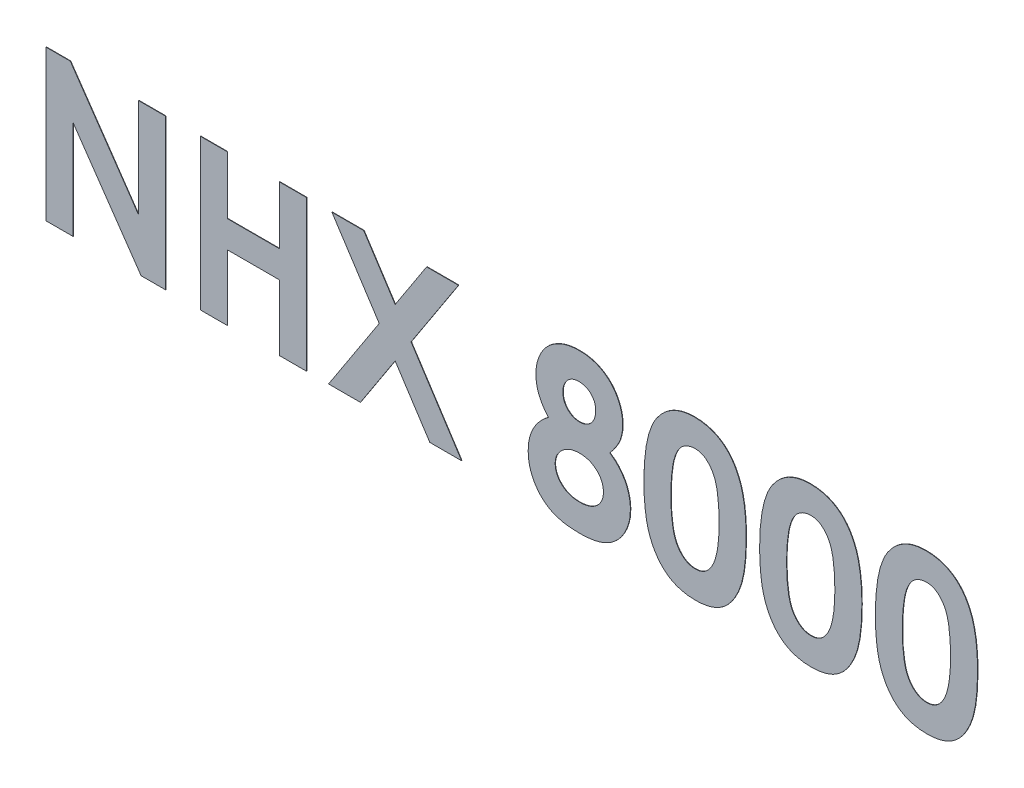
from build123d import *

# Parameters (mm, degrees)
ESTRUSIONE_ESTRUSIONE1_DEPTH   = 0.01
ESTRUSIONE_ESTRUSIONE1_2_DEPTH = 0.01
ESTRUSIONE_ESTRUSIONE1_3_DEPTH = 0.01
ESTRUSIONE_ESTRUSIONE1_4_DEPTH = 0.01
ESTRUSIONE_ESTRUSIONE1_5_DEPTH = 0.01
ESTRUSIONE_ESTRUSIONE1_6_DEPTH = 0.01
ESTRUSIONE_ESTRUSIONE1_7_DEPTH = 0.01
SCALA1_SCALE                   = 40


with BuildPart() as part:
    # Schizzo1 → Estrusione-Estrusione1 (new body)
    with BuildSketch(Plane.XY):
        Polygon((0.403846154, 3.5), (0.969651442, 3.5), (2.557692308, 1.196814904), (2.557692308, 3.5), (3.185897436, 3.5), (3.185897436, 0), (2.615885417, 0), (1.032051282, 2.296173878), (1.032051282, 0), (0.403846154, 0), align=None)
    extrude(amount=ESTRUSIONE_ESTRUSIONE1_DEPTH)


with BuildPart() as body_2:
    # Schizzo1 → Estrusione-Estrusione1 2 (new body)
    with BuildSketch(Plane.XY):
        Polygon((3.993589744, 3.5), (4.621794872, 3.5), (4.621794872, 2.153846154), (5.833333333, 2.153846154), (5.833333333, 3.5), (6.461538462, 3.5), (6.461538462, 0), (5.833333333, 0), (5.833333333, 1.525641026), (4.621794872, 1.525641026), (4.621794872, 0), (3.993589744, 0), align=None)
    extrude(amount=ESTRUSIONE_ESTRUSIONE1_2_DEPTH)


with BuildPart() as body_3:
    # Schizzo1 → Estrusione-Estrusione1 3 (new body)
    with BuildSketch(Plane.XY):
        Polygon((7.055388622, 3.5), (7.795773237, 3.5), (8.527043269, 2.376101763), (9.259715545, 3.5), (10.000801282, 3.5), (8.897235577, 1.807491987), (10.073717949, 0), (9.333333333, 0), (8.527043269, 1.239583333), (7.71864984, 0), (6.977564103, 0), (8.156850962, 1.808193109), align=None)
    extrude(amount=ESTRUSIONE_ESTRUSIONE1_3_DEPTH)


with BuildPart() as body_4:
    # Schizzo1 → Estrusione-Estrusione1 4 (new body)
    with BuildSketch(Plane.XY):
        with BuildLine():
            add(Edge.make_bspline(
                [(13.520432692, 1.884615385), (13.557134601, 1.85839088), (13.629782717, 1.806481838), (13.725724304, 1.713484848), (13.808363459, 1.609745628), (13.87683238, 1.495900492), (13.931687615, 1.374747784), (13.97095564, 1.247582481), (13.995898238, 1.115526214), (13.998622715, 1.025618623), (14, 0.980168269)],
                knots=[0, 0, 0, 0, 0.000135177, 0.00026757, 0.000399295, 0.000532042, 0.000665095, 0.000797263, 0.000930523, 0.001066759, 0.001066759, 0.001066759, 0.001066759], degree=3))
            add(Edge.make_bspline(
                [(14, 0.980168269), (13.99833841, 0.930953536), (13.995042859, 0.833342428), (13.965905788, 0.690195753), (13.919127389, 0.552673083), (13.855195578, 0.422292319), (13.775036845, 0.303105196), (13.681604387, 0.197590627), (13.574780425, 0.108504305), (13.47532429, 0.048059811), (13.38971892, 0.007907676), (13.320636138, -0.017788884), (13.247689261, -0.04041111), (13.17035775, -0.058484767), (13.088655668, -0.072594223), (13.002699613, -0.081912081), (12.912433003, -0.088685596), (12.850874991, -0.089384979), (12.819310897, -0.08974359)],
                knots=[0, 0, 0, 0, 0.000147517, 0.000292582, 0.000436255, 0.000582373, 0.000726855, 0.000865897, 0.001003783, 0.001142545, 0.001213746, 0.00128719, 0.00136348, 0.001442728, 0.001525259, 0.001612053, 0.001702019, 0.001796693, 0.001796693, 0.001796693, 0.001796693], degree=3))
            add(Edge.make_bspline(
                [(12.819310897, -0.08974359), (12.785650923, -0.089287007), (12.71991963, -0.08839539), (12.623966585, -0.083004204), (12.533454516, -0.073064948), (12.448193559, -0.059980687), (12.368265746, -0.042666417), (12.293668707, -0.020712871), (12.224222321, 0.004283683), (12.139216297, 0.042343082), (12.042069826, 0.101780984), (11.93707206, 0.188826078), (11.844910884, 0.292499504), (11.76478547, 0.409891165), (11.701627599, 0.540278868), (11.654661523, 0.679570167), (11.626847657, 0.8273876), (11.623499179, 0.928635274), (11.621794872, 0.980168269)],
                knots=[0, 0, 0, 0, 0.000100983, 0.000197201, 0.000288177, 0.000374052, 0.000455879, 0.000533311, 0.000607169, 0.000677148, 0.00081242, 0.000947344, 0.001084873, 0.00122722, 0.001372399, 0.001518066, 0.00166713, 0.001821645, 0.001821645, 0.001821645, 0.001821645], degree=3))
            add(Edge.make_bspline(
                [(11.621794872, 0.980168269), (11.623352323, 1.02512233), (11.626412903, 1.113462503), (11.64833625, 1.242908796), (11.685928128, 1.365639198), (11.737510036, 1.482508108), (11.804024031, 1.59352853), (11.885863437, 1.697883573), (11.981990615, 1.796514663), (12.054885649, 1.854761362), (12.092247596, 1.884615385)],
                knots=[0, 0, 0, 0, 0.000134836, 0.000264969, 0.000392498, 0.000519, 0.000647297, 0.000779691, 0.000916035, 0.001059397, 0.001059397, 0.001059397, 0.001059397], degree=3))
            add(Edge.make_bspline(
                [(12.092247596, 1.884615385), (12.069085171, 1.911329853), (12.023485331, 1.963922597), (11.96447869, 2.048566426), (11.91476808, 2.135834303), (11.872561405, 2.225018003), (11.841361155, 2.317653045), (11.817766573, 2.412283019), (11.8044215, 2.509871987), (11.802335625, 2.575649851), (11.801282051, 2.608874199)],
                knots=[0, 0, 0, 0, 0.000106018, 0.000208717, 0.000308899, 0.000407081, 0.000504196, 0.000601634, 0.000699302, 0.000798982, 0.000798982, 0.000798982, 0.000798982], degree=3))
            add(Edge.make_bspline(
                [(11.801282051, 2.608874199), (11.80267893, 2.653850171), (11.805434918, 2.742586032), (11.829844543, 2.872338813), (11.870370447, 2.995629814), (11.925502491, 3.11209806), (11.995511619, 3.21920525), (12.078697619, 3.315256457), (12.176229923, 3.39673336), (12.284481567, 3.46664414), (12.40399516, 3.522250526), (12.533636768, 3.56115971), (12.671840951, 3.585791276), (12.767087147, 3.58840611), (12.815805288, 3.58974359)],
                knots=[0, 0, 0, 0, 0.000134836, 0.000266026, 0.000394401, 0.000523295, 0.000651447, 0.000777159, 0.000903019, 0.001031378, 0.00116281, 0.001296988, 0.001436461, 0.001582498, 0.001582498, 0.001582498, 0.001582498], degree=3))
            add(Edge.make_bspline(
                [(12.815805288, 3.58974359), (12.863821761, 3.588403921), (12.957443829, 3.585791847), (13.093219257, 3.561323492), (13.220059285, 3.521547598), (13.336915038, 3.464767113), (13.44404715, 3.394721588), (13.539921818, 3.310407735), (13.622846778, 3.211964217), (13.693437026, 3.102086196), (13.749686607, 2.983708548), (13.791271722, 2.859565009), (13.815325045, 2.730631358), (13.818776647, 2.643091493), (13.820512821, 2.599058494)],
                knots=[0, 0, 0, 0, 0.000143937, 0.000280646, 0.000412357, 0.000541553, 0.000669119, 0.000795294, 0.000923131, 0.001054017, 0.001186046, 0.001315306, 0.001445807, 0.001577886, 0.001577886, 0.001577886, 0.001577886], degree=3))
            add(Edge.make_bspline(
                [(13.820512821, 2.599058494), (13.819676464, 2.567938351), (13.818035177, 2.506867397), (13.80589983, 2.416892646), (13.785465395, 2.330561752), (13.756975166, 2.245788452), (13.717364023, 2.160268983), (13.663760936, 2.072364636), (13.598559819, 1.978422968), (13.547354125, 1.916940066), (13.520432692, 1.884615385)],
                knots=[0, 0, 0, 0, 9.3344e-05, 0.000183181, 0.000271783, 0.00035914, 0.000451054, 0.000553861, 0.000667646, 0.000793787, 0.000793787, 0.000793787, 0.000793787], degree=3))
        make_face()
        with BuildLine():
            add(Edge.make_bspline(
                [(12.800380609, 2.961538462), (12.774516092, 2.960291552), (12.724203892, 2.957866039), (12.652414274, 2.935973092), (12.587873065, 2.90016562), (12.532053546, 2.850887492), (12.48627863, 2.791095866), (12.452636582, 2.722353174), (12.43268645, 2.645507777), (12.43057434, 2.591699174), (12.429487179, 2.564002404)],
                knots=[0, 0, 0, 0, 7.7441e-05, 0.000150641, 0.000222826, 0.000297356, 0.000372379, 0.000447321, 0.000525545, 0.000608518, 0.000608518, 0.000608518, 0.000608518], degree=3))
            add(Edge.make_bspline(
                [(12.429487179, 2.564002404), (12.430830156, 2.536069098), (12.433452446, 2.481526625), (12.454073813, 2.403204778), (12.489223504, 2.332222912), (12.537483792, 2.270063604), (12.596127857, 2.219293679), (12.661791232, 2.180518436), (12.735202136, 2.158382655), (12.78621567, 2.155380965), (12.812299679, 2.153846154)],
                knots=[0, 0, 0, 0, 8.3728e-05, 0.000163486, 0.000240934, 0.00031989, 0.000397917, 0.000472358, 0.000547102, 0.000625308, 0.000625308, 0.000625308, 0.000625308], degree=3))
            add(Edge.make_bspline(
                [(12.812299679, 2.153846154), (12.838876821, 2.155035369), (12.89065408, 2.157352184), (12.964248281, 2.180062326), (13.030547252, 2.21638257), (13.087322525, 2.267731361), (13.134349892, 2.32991318), (13.168598837, 2.402135517), (13.188311293, 2.483041407), (13.190942976, 2.539587197), (13.192307692, 2.568910256)],
                knots=[0, 0, 0, 0, 7.9536e-05, 0.000154952, 0.000228703, 0.000304687, 0.000382792, 0.000461195, 0.000542818, 0.000630738, 0.000630738, 0.000630738, 0.000630738], degree=3))
            add(Edge.make_bspline(
                [(13.192307692, 2.568910256), (13.190908454, 2.596588717), (13.188202376, 2.650117887), (13.168798761, 2.726968269), (13.133163051, 2.794638052), (13.086342326, 2.854058384), (13.027641684, 2.901977186), (12.959494539, 2.937216962), (12.882402697, 2.957656374), (12.82831337, 2.96021641), (12.800380609, 2.961538462)],
                knots=[0, 0, 0, 0, 8.3029e-05, 0.000160575, 0.00023552, 0.000310854, 0.000386083, 0.000461028, 0.000539431, 0.000623159, 0.000623159, 0.000623159, 0.000623159], degree=3))
        make_face(mode=Mode.SUBTRACT)
        with BuildLine():
            add(Edge.make_bspline(
                [(12.820713141, 1.525641026), (12.801058066, 1.525314624), (12.762318159, 1.52467129), (12.705367311, 1.517252686), (12.650717121, 1.50619713), (12.598435388, 1.490946303), (12.548786239, 1.470155589), (12.501348813, 1.445091998), (12.456286937, 1.41550217), (12.414269006, 1.381923308), (12.376294614, 1.345067308), (12.342064154, 1.306627695), (12.314085586, 1.2656107), (12.290786109, 1.223379742), (12.272064848, 1.179600163), (12.259688679, 1.133551003), (12.251720159, 1.085845509), (12.25057676, 1.053350461), (12.25, 1.036959135)],
                knots=[0, 0, 0, 0, 5.8932e-05, 0.000116154, 0.00017198, 0.000226107, 0.000279231, 0.000333176, 0.000386848, 0.00044072, 0.000494272, 0.000545454, 0.000594852, 0.000642862, 0.000689999, 0.000737287, 0.000785583, 0.000834742, 0.000834742, 0.000834742, 0.000834742], degree=3))
            add(Edge.make_bspline(
                [(12.25, 1.036959135), (12.250274894, 1.0198646), (12.250820112, 0.985959705), (12.259054864, 0.936472773), (12.270911454, 0.888746025), (12.287564412, 0.843226213), (12.30983458, 0.799939838), (12.336425565, 0.758466064), (12.368264584, 0.719095711), (12.404488331, 0.682039869), (12.445040656, 0.648608885), (12.488747175, 0.619155605), (12.535030625, 0.593188086), (12.585280402, 0.57448525), (12.637635557, 0.557366772), (12.6934987, 0.546981403), (12.752259681, 0.539339561), (12.79240676, 0.538759229), (12.813000801, 0.538461538)],
                knots=[0, 0, 0, 0, 5.1225e-05, 0.000101599, 0.000150062, 0.000198643, 0.000246617, 0.00029582, 0.000346189, 0.000398247, 0.000451032, 0.000503536, 0.000556247, 0.000609757, 0.000664089, 0.000721289, 0.000779903, 0.000841638, 0.000841638, 0.000841638, 0.000841638], degree=3))
            add(Edge.make_bspline(
                [(12.813000801, 0.538461538), (12.833818314, 0.538838881), (12.874385053, 0.539574201), (12.933685468, 0.546073039), (12.989773136, 0.556384806), (13.042581063, 0.571133034), (13.092308944, 0.590026101), (13.138289721, 0.614073237), (13.181573212, 0.641325334), (13.220768498, 0.673163934), (13.256556683, 0.707861361), (13.28739323, 0.745886791), (13.313613203, 0.786017464), (13.334762469, 0.828686989), (13.351828027, 0.873693952), (13.363533929, 0.921487118), (13.370797862, 0.971529403), (13.371458967, 1.005616963), (13.371794872, 1.022936699)],
                knots=[0, 0, 0, 0, 6.2435e-05, 0.000121667, 0.000178734, 0.00023334, 0.000285943, 0.000337996, 0.000388759, 0.000439127, 0.000489202, 0.00053804, 0.000585685, 0.000632718, 0.000680641, 0.000729785, 0.000780056, 0.000831981, 0.000831981, 0.000831981, 0.000831981], degree=3))
            add(Edge.make_bspline(
                [(13.371794872, 1.022936699), (13.371153492, 1.040482865), (13.369899818, 1.074779539), (13.363039895, 1.125426645), (13.350171381, 1.173440894), (13.333335605, 1.219935855), (13.310940157, 1.263949395), (13.283136693, 1.305388621), (13.251489526, 1.345280033), (13.214500981, 1.381847811), (13.174059758, 1.415283757), (13.131016523, 1.445071515), (13.085503852, 1.470298998), (13.037397255, 1.490921213), (12.986520961, 1.506205066), (12.933263157, 1.517252297), (12.877711207, 1.52467295), (12.839901481, 1.525315124), (12.820713141, 1.525641026)],
                knots=[0, 0, 0, 0, 5.2659e-05, 0.00010293, 0.000152926, 0.000201506, 0.000251049, 0.000300635, 0.000351004, 0.000403555, 0.00045634, 0.000508266, 0.000560361, 0.000612192, 0.000664977, 0.00071943, 0.000775261, 0.000832791, 0.000832791, 0.000832791, 0.000832791], degree=3))
        make_face(mode=Mode.SUBTRACT)
    extrude(amount=ESTRUSIONE_ESTRUSIONE1_4_DEPTH)


with BuildPart() as body_5:
    # Schizzo1 → Estrusione-Estrusione1 5 (new body)
    with BuildSketch(Plane.XY):
        with BuildLine():
            add(Edge.make_bspline(
                [(15.492688301, 3.58974359), (15.523096037, 3.589292178), (15.582885769, 3.588404583), (15.670944791, 3.578791201), (15.755769975, 3.564268063), (15.837693169, 3.544013349), (15.916124681, 3.517206957), (15.991635353, 3.485120165), (16.063326387, 3.446069956), (16.132112075, 3.401960738), (16.19796592, 3.352022851), (16.25930517, 3.29509108), (16.317250012, 3.23247543), (16.370546152, 3.163229263), (16.420373849, 3.087982447), (16.466569379, 3.00672305), (16.508779103, 2.919053361), (16.547476091, 2.824815174), (16.582079059, 2.722595899), (16.611225097, 2.611223037), (16.636222702, 2.490671153), (16.657322443, 2.360640176), (16.673270438, 2.220957264), (16.684019708, 2.071715214), (16.691396365, 1.913201744), (16.691998396, 1.804462806), (16.692307692, 1.748597756)],
                knots=[0, 0, 0, 0, 9.1189e-05, 0.000179302, 0.000265406, 0.000349239, 0.000432161, 0.00051382, 0.000595069, 0.000676752, 0.000758786, 0.000842642, 0.00092749, 0.00101444, 0.001104474, 0.001198046, 0.001294628, 0.001396185, 0.001503495, 0.001618119, 0.001741326, 0.001872727, 0.002013179, 0.002162939, 0.002321548, 0.002489129, 0.002489129, 0.002489129, 0.002489129], degree=3))
            add(Edge.make_bspline(
                [(16.692307692, 1.748597756), (16.691973427, 1.692033772), (16.691323955, 1.582130965), (16.684326357, 1.42216765), (16.672276163, 1.271842014), (16.656745002, 1.131169608), (16.635471561, 1.000224719), (16.610557404, 0.878668289), (16.580951305, 0.766544378), (16.545208525, 0.664105625), (16.506745771, 0.569701935), (16.464420586, 0.482203181), (16.418970691, 0.401372369), (16.371438571, 0.325990055), (16.31921834, 0.258278471), (16.264851703, 0.195935071), (16.20597144, 0.141334593), (16.145056639, 0.091663175), (16.079875742, 0.048737102), (16.011100945, 0.011194666), (15.937506111, -0.019256709), (15.860432749, -0.045741688), (15.778567128, -0.064755045), (15.693210081, -0.07984152), (15.603397946, -0.088179231), (15.542250227, -0.089213579), (15.510917468, -0.08974359)],
                knots=[0, 0, 0, 0, 0.000169685, 0.000329694, 0.000480207, 0.000622052, 0.000754146, 0.000878038, 0.000994198, 0.001101735, 0.001203292, 0.001299874, 0.001393102, 0.001481398, 0.001566938, 0.001649385, 0.001729242, 0.001807533, 0.001884926, 0.001963041, 0.002042215, 0.002123584, 0.00220725, 0.002294045, 0.002383484, 0.002477476, 0.002477476, 0.002477476, 0.002477476], degree=3))
            add(Edge.make_bspline(
                [(15.510917468, -0.08974359), (15.479585555, -0.089203355), (15.418206798, -0.088145043), (15.328151802, -0.079903514), (15.242342406, -0.06469393), (15.159829097, -0.045595718), (15.081186153, -0.01931531), (15.006036485, 0.012047148), (14.934957928, 0.049355338), (14.867753677, 0.092381425), (14.804653186, 0.141720504), (14.744675875, 0.196844838), (14.687954416, 0.257614701), (14.635351683, 0.324710765), (14.586006197, 0.397237439), (14.540432551, 0.476022941), (14.498658136, 0.560952561), (14.459376239, 0.652144684), (14.425245243, 0.75156257), (14.394870241, 0.860094009), (14.369987838, 0.9786437), (14.349975745, 1.107173557), (14.333998101, 1.245411285), (14.322112571, 1.393423606), (14.315076104, 1.551279462), (14.314433444, 1.659781655), (14.314102564, 1.715645032)],
                knots=[0, 0, 0, 0, 9.3992e-05, 0.000184129, 0.000270924, 0.000355272, 0.000437971, 0.000519356, 0.000599327, 0.000678482, 0.000758422, 0.000839307, 0.000922649, 0.001007511, 0.001094825, 0.001185617, 0.00128031, 0.001378632, 0.00148329, 0.001595393, 0.001716541, 0.001846447, 0.001985506, 0.002133922, 0.00229183, 0.002459412, 0.002459412, 0.002459412, 0.002459412], degree=3))
            add(Edge.make_bspline(
                [(14.314102564, 1.715645032), (14.314701922, 1.793262797), (14.315858391, 1.943027275), (14.330514011, 2.159393402), (14.352024745, 2.359386406), (14.383618917, 2.542671749), (14.422684674, 2.709928265), (14.47271041, 2.860054156), (14.529661071, 2.995126752), (14.578190351, 3.075144571), (14.6015625, 3.113681891)],
                knots=[0, 0, 0, 0, 0.00023281, 0.000449211, 0.000650286, 0.000835979, 0.001006883, 0.001164965, 0.001310334, 0.001445389, 0.001445389, 0.001445389, 0.001445389], degree=3))
            add(Edge.make_bspline(
                [(14.6015625, 3.113681891), (14.628738522, 3.151540942), (14.681873, 3.225562848), (14.77478012, 3.322739774), (14.874596724, 3.405850239), (14.983372988, 3.47301338), (15.09938857, 3.525978238), (15.223639524, 3.563386721), (15.35566701, 3.585182647), (15.446332487, 3.588200572), (15.492688301, 3.58974359)],
                knots=[0, 0, 0, 0, 0.000139664, 0.000273071, 0.000402072, 0.00052834, 0.000655415, 0.000783615, 0.000916514, 0.00105555, 0.00105555, 0.00105555, 0.00105555], degree=3))
        make_face()
        with BuildLine():
            add(Edge.make_bspline(
                [(15.508112981, 2.961538462), (15.480624136, 2.960235545), (15.426731407, 2.957681137), (15.348530491, 2.935997815), (15.274791909, 2.902506756), (15.218700939, 2.862205503), (15.176717406, 2.823571918), (15.147383211, 2.788609781), (15.119095003, 2.749594555), (15.094109432, 2.704765685), (15.070516532, 2.655733924), (15.047459157, 2.602276698), (15.028558164, 2.543080981), (15.00998844, 2.479154885), (14.993719628, 2.408731022), (14.980089931, 2.331233756), (14.967912995, 2.246159114), (14.959419436, 2.153451372), (14.951500891, 2.053207526), (14.945824502, 1.945204271), (14.943451347, 1.829470744), (14.942696993, 1.749766781), (14.942307692, 1.708633814)],
                knots=[0, 0, 0, 0, 8.233e-05, 0.000161411, 0.000241719, 0.000324202, 0.000367359, 0.000412607, 0.000460858, 0.000511731, 0.000566293, 0.000624109, 0.000686189, 0.000752544, 0.000823804, 0.000902881, 0.00098855, 0.001081546, 0.001182103, 0.001290221, 0.00140594, 0.001529346, 0.001529346, 0.001529346, 0.001529346], degree=3))
            add(Edge.make_bspline(
                [(14.942307692, 1.708633814), (14.942948434, 1.655344067), (14.944177104, 1.553157026), (14.950612303, 1.406208503), (14.963511126, 1.272473515), (14.979554657, 1.151045689), (15.002088451, 1.042712518), (15.02801504, 0.94644907), (15.060032073, 0.86348247), (15.097033923, 0.792612834), (15.138015139, 0.732324181), (15.182502051, 0.681078555), (15.228980041, 0.636702261), (15.278899836, 0.600655944), (15.332142344, 0.573031708), (15.388263087, 0.553161936), (15.447297729, 0.540998822), (15.487724044, 0.539312189), (15.508112981, 0.538461538)],
                knots=[0, 0, 0, 0, 0.00015988, 0.000306582, 0.00044109, 0.000562851, 0.000673817, 0.000772822, 0.000861618, 0.000940022, 0.001012169, 0.001079776, 0.001143265, 0.001204556, 0.001263825, 0.001322589, 0.001382678, 0.00144382, 0.00144382, 0.00144382, 0.00144382], degree=3))
            add(Edge.make_bspline(
                [(15.508112981, 0.538461538), (15.527802234, 0.539043617), (15.566351344, 0.540183253), (15.62256458, 0.551881469), (15.675723809, 0.570900227), (15.725668529, 0.597803595), (15.772577384, 0.632015344), (15.816221113, 0.673685815), (15.856270564, 0.723230366), (15.879603555, 0.759999749), (15.891626603, 0.778946314)],
                knots=[0, 0, 0, 0, 5.8998e-05, 0.000115512, 0.000171399, 0.00022786, 0.000285078, 0.000345085, 0.000408376, 0.000475658, 0.000475658, 0.000475658, 0.000475658], degree=3))
            add(Edge.make_bspline(
                [(15.891626603, 0.778946314), (15.905781716, 0.804836189), (15.93546384, 0.859125158), (15.969812045, 0.950735767), (15.99872445, 1.054057394), (16.023608935, 1.169411585), (16.040628404, 1.29725331), (16.05528555, 1.436771915), (16.062355056, 1.588669958), (16.063504949, 1.69390547), (16.064102564, 1.748597756)],
                knots=[0, 0, 0, 0, 8.843e-05, 0.000185431, 0.00029262, 0.000410194, 0.000539093, 0.000679319, 0.000830958, 0.000995045, 0.000995045, 0.000995045, 0.000995045], degree=3))
            add(Edge.make_bspline(
                [(16.064102564, 1.748597756), (16.063871718, 1.803764798), (16.06342738, 1.909951935), (16.055275053, 2.062396063), (16.043922315, 2.201628473), (16.027316536, 2.327338316), (16.005950184, 2.439830761), (15.979616074, 2.539098454), (15.948570117, 2.625337033), (15.911753312, 2.698460505), (15.870976413, 2.760605426), (15.82769049, 2.813920947), (15.781712513, 2.859440394), (15.733119371, 2.897335064), (15.680786359, 2.926289435), (15.625713107, 2.946733616), (15.567786709, 2.959101659), (15.528272705, 2.960715231), (15.508112981, 2.961538462)],
                knots=[0, 0, 0, 0, 0.000165478, 0.000318517, 0.00045785, 0.000584474, 0.000698739, 0.000801125, 0.000892295, 0.000973192, 0.001046115, 0.001114882, 0.001178838, 0.00123984, 0.001299154, 0.001357499, 0.001415527, 0.00147597, 0.00147597, 0.00147597, 0.00147597], degree=3))
        make_face(mode=Mode.SUBTRACT)
    extrude(amount=ESTRUSIONE_ESTRUSIONE1_5_DEPTH)


with BuildPart() as body_6:
    # Schizzo1 → Estrusione-Estrusione1 6 (new body)
    with BuildSketch(Plane.XY):
        with BuildLine():
            add(Edge.make_bspline(
                [(18.184995994, 3.58974359), (18.215403729, 3.589292178), (18.275193462, 3.588404583), (18.363252483, 3.578791201), (18.448077667, 3.564268063), (18.530000862, 3.544013349), (18.608432374, 3.517206957), (18.683943045, 3.485120165), (18.75563408, 3.446069956), (18.824419767, 3.401960738), (18.890273612, 3.352022851), (18.951612863, 3.29509108), (19.009557704, 3.23247543), (19.062853844, 3.163229263), (19.112681541, 3.087982447), (19.158877071, 3.00672305), (19.201086795, 2.919053361), (19.239783783, 2.824815174), (19.274386752, 2.722595899), (19.303532789, 2.611223037), (19.328530394, 2.490671153), (19.349630136, 2.360640176), (19.36557813, 2.220957264), (19.3763274, 2.071715214), (19.383704057, 1.913201744), (19.384306089, 1.804462806), (19.384615385, 1.748597756)],
                knots=[0, 0, 0, 0, 9.1189e-05, 0.000179302, 0.000265406, 0.000349239, 0.000432161, 0.00051382, 0.000595069, 0.000676752, 0.000758786, 0.000842642, 0.00092749, 0.00101444, 0.001104474, 0.001198046, 0.001294628, 0.001396185, 0.001503495, 0.001618119, 0.001741326, 0.001872727, 0.002013179, 0.002162939, 0.002321548, 0.002489129, 0.002489129, 0.002489129, 0.002489129], degree=3))
            add(Edge.make_bspline(
                [(19.384615385, 1.748597756), (19.384281119, 1.692033772), (19.383631648, 1.582130965), (19.37663405, 1.42216765), (19.364583855, 1.271842014), (19.349052695, 1.131169608), (19.327779253, 1.000224719), (19.302865096, 0.878668289), (19.273258997, 0.766544378), (19.237516218, 0.664105625), (19.199053463, 0.569701935), (19.156728278, 0.482203181), (19.111278383, 0.401372369), (19.063746263, 0.325990055), (19.011526032, 0.258278471), (18.957159395, 0.195935071), (18.898279133, 0.141334593), (18.837364331, 0.091663175), (18.772183435, 0.048737102), (18.703408637, 0.011194666), (18.629813803, -0.019256709), (18.552740441, -0.045741688), (18.47087482, -0.064755045), (18.385517774, -0.07984152), (18.295705638, -0.088179231), (18.234557919, -0.089213579), (18.20322516, -0.08974359)],
                knots=[0, 0, 0, 0, 0.000169685, 0.000329694, 0.000480207, 0.000622052, 0.000754146, 0.000878038, 0.000994198, 0.001101735, 0.001203292, 0.001299874, 0.001393102, 0.001481398, 0.001566938, 0.001649385, 0.001729242, 0.001807533, 0.001884926, 0.001963041, 0.002042215, 0.002123584, 0.00220725, 0.002294045, 0.002383484, 0.002477476, 0.002477476, 0.002477476, 0.002477476], degree=3))
            add(Edge.make_bspline(
                [(18.20322516, -0.08974359), (18.171893247, -0.089203355), (18.110514491, -0.088145043), (18.020459494, -0.079903514), (17.934650098, -0.06469393), (17.852136789, -0.045595718), (17.773493845, -0.01931531), (17.698344177, 0.012047148), (17.62726562, 0.049355338), (17.560061369, 0.092381425), (17.496960879, 0.141720504), (17.436983567, 0.196844838), (17.380262108, 0.257614701), (17.327659376, 0.324710765), (17.278313889, 0.397237439), (17.232740244, 0.476022941), (17.190965828, 0.560952561), (17.151683931, 0.652144684), (17.117552935, 0.75156257), (17.087177933, 0.860094009), (17.06229553, 0.9786437), (17.042283437, 1.107173557), (17.026305794, 1.245411285), (17.014420263, 1.393423606), (17.007383797, 1.551279462), (17.006741136, 1.659781655), (17.006410256, 1.715645032)],
                knots=[0, 0, 0, 0, 9.3992e-05, 0.000184129, 0.000270924, 0.000355272, 0.000437971, 0.000519356, 0.000599327, 0.000678482, 0.000758422, 0.000839307, 0.000922649, 0.001007511, 0.001094825, 0.001185617, 0.00128031, 0.001378632, 0.00148329, 0.001595393, 0.001716541, 0.001846447, 0.001985506, 0.002133922, 0.00229183, 0.002459412, 0.002459412, 0.002459412, 0.002459412], degree=3))
            add(Edge.make_bspline(
                [(17.006410256, 1.715645032), (17.007009614, 1.793262797), (17.008166083, 1.943027275), (17.022821703, 2.159393402), (17.044332437, 2.359386406), (17.075926609, 2.542671749), (17.114992366, 2.709928265), (17.165018102, 2.860054156), (17.221968763, 2.995126752), (17.270498043, 3.075144571), (17.293870192, 3.113681891)],
                knots=[0, 0, 0, 0, 0.00023281, 0.000449211, 0.000650286, 0.000835979, 0.001006883, 0.001164965, 0.001310334, 0.001445389, 0.001445389, 0.001445389, 0.001445389], degree=3))
            add(Edge.make_bspline(
                [(17.293870192, 3.113681891), (17.321046214, 3.151540942), (17.374180692, 3.225562848), (17.467087812, 3.322739774), (17.566904416, 3.405850239), (17.67568068, 3.47301338), (17.791696262, 3.525978238), (17.915947216, 3.563386721), (18.047974702, 3.585182647), (18.13864018, 3.588200572), (18.184995994, 3.58974359)],
                knots=[0, 0, 0, 0, 0.000139664, 0.000273071, 0.000402072, 0.00052834, 0.000655415, 0.000783615, 0.000916514, 0.00105555, 0.00105555, 0.00105555, 0.00105555], degree=3))
        make_face()
        with BuildLine():
            add(Edge.make_bspline(
                [(18.200420673, 2.961538462), (18.172931828, 2.960235545), (18.1190391, 2.957681137), (18.040838183, 2.935997815), (17.967099601, 2.902506756), (17.911008631, 2.862205503), (17.869025099, 2.823571918), (17.839690903, 2.788609781), (17.811402695, 2.749594555), (17.786417125, 2.704765685), (17.762824225, 2.655733924), (17.73976685, 2.602276698), (17.720865857, 2.543080981), (17.702296132, 2.479154885), (17.686027321, 2.408731022), (17.672397623, 2.331233756), (17.660220687, 2.246159114), (17.651727128, 2.153451372), (17.643808583, 2.053207526), (17.638132195, 1.945204271), (17.635759039, 1.829470744), (17.635004685, 1.749766781), (17.634615385, 1.708633814)],
                knots=[0, 0, 0, 0, 8.233e-05, 0.000161411, 0.000241719, 0.000324202, 0.000367359, 0.000412607, 0.000460858, 0.000511731, 0.000566293, 0.000624109, 0.000686189, 0.000752544, 0.000823804, 0.000902881, 0.00098855, 0.001081546, 0.001182103, 0.001290221, 0.00140594, 0.001529346, 0.001529346, 0.001529346, 0.001529346], degree=3))
            add(Edge.make_bspline(
                [(17.634615385, 1.708633814), (17.635256126, 1.655344067), (17.636484796, 1.553157026), (17.642919996, 1.406208503), (17.655818818, 1.272473515), (17.671862349, 1.151045689), (17.694396144, 1.042712518), (17.720322733, 0.94644907), (17.752339765, 0.86348247), (17.789341615, 0.792612834), (17.830322831, 0.732324181), (17.874809744, 0.681078555), (17.921287733, 0.636702261), (17.971207529, 0.600655944), (18.024450036, 0.573031708), (18.080570779, 0.553161936), (18.139605422, 0.540998822), (18.180031736, 0.539312189), (18.200420673, 0.538461538)],
                knots=[0, 0, 0, 0, 0.00015988, 0.000306582, 0.00044109, 0.000562851, 0.000673817, 0.000772822, 0.000861618, 0.000940022, 0.001012169, 0.001079776, 0.001143265, 0.001204556, 0.001263825, 0.001322589, 0.001382678, 0.00144382, 0.00144382, 0.00144382, 0.00144382], degree=3))
            add(Edge.make_bspline(
                [(18.200420673, 0.538461538), (18.220109926, 0.539043617), (18.258659036, 0.540183253), (18.314872272, 0.551881469), (18.368031502, 0.570900227), (18.417976222, 0.597803595), (18.464885077, 0.632015344), (18.508528806, 0.673685815), (18.548578256, 0.723230366), (18.571911248, 0.759999749), (18.583934295, 0.778946314)],
                knots=[0, 0, 0, 0, 5.8998e-05, 0.000115512, 0.000171399, 0.00022786, 0.000285078, 0.000345085, 0.000408376, 0.000475658, 0.000475658, 0.000475658, 0.000475658], degree=3))
            add(Edge.make_bspline(
                [(18.583934295, 0.778946314), (18.598089408, 0.804836189), (18.627771532, 0.859125158), (18.662119738, 0.950735767), (18.691032143, 1.054057394), (18.715916627, 1.169411585), (18.732936096, 1.29725331), (18.747593242, 1.436771915), (18.754662748, 1.588669958), (18.755812641, 1.69390547), (18.756410256, 1.748597756)],
                knots=[0, 0, 0, 0, 8.843e-05, 0.000185431, 0.00029262, 0.000410194, 0.000539093, 0.000679319, 0.000830958, 0.000995045, 0.000995045, 0.000995045, 0.000995045], degree=3))
            add(Edge.make_bspline(
                [(18.756410256, 1.748597756), (18.756179411, 1.803764798), (18.755735072, 1.909951935), (18.747582745, 2.062396063), (18.736230007, 2.201628473), (18.719624228, 2.327338316), (18.698257876, 2.439830761), (18.671923766, 2.539098454), (18.640877809, 2.625337033), (18.604061004, 2.698460505), (18.563284106, 2.760605426), (18.519998183, 2.813920947), (18.474020205, 2.859440394), (18.425427063, 2.897335064), (18.373094052, 2.926289435), (18.318020799, 2.946733616), (18.260094401, 2.959101659), (18.220580397, 2.960715231), (18.200420673, 2.961538462)],
                knots=[0, 0, 0, 0, 0.000165478, 0.000318517, 0.00045785, 0.000584474, 0.000698739, 0.000801125, 0.000892295, 0.000973192, 0.001046115, 0.001114882, 0.001178838, 0.00123984, 0.001299154, 0.001357499, 0.001415527, 0.00147597, 0.00147597, 0.00147597, 0.00147597], degree=3))
        make_face(mode=Mode.SUBTRACT)
    extrude(amount=ESTRUSIONE_ESTRUSIONE1_6_DEPTH)


with BuildPart() as body_7:
    # Schizzo1 → Estrusione-Estrusione1 7 (new body)
    with BuildSketch(Plane.XY):
        with BuildLine():
            add(Edge.make_bspline(
                [(20.877303686, 3.58974359), (20.907711421, 3.589292178), (20.967501154, 3.588404583), (21.055560175, 3.578791201), (21.14038536, 3.564268063), (21.222308554, 3.544013349), (21.300740066, 3.517206957), (21.376250737, 3.485120165), (21.447941772, 3.446069956), (21.51672746, 3.401960738), (21.582581305, 3.352022851), (21.643920555, 3.29509108), (21.701865397, 3.23247543), (21.755161536, 3.163229263), (21.804989234, 3.087982447), (21.851184763, 3.00672305), (21.893394487, 2.919053361), (21.932091475, 2.824815174), (21.966694444, 2.722595899), (21.995840482, 2.611223037), (22.020838086, 2.490671153), (22.041937828, 2.360640176), (22.057885823, 2.220957264), (22.068635092, 2.071715214), (22.07601175, 1.913201744), (22.076613781, 1.804462806), (22.076923077, 1.748597756)],
                knots=[0, 0, 0, 0, 9.1189e-05, 0.000179302, 0.000265406, 0.000349239, 0.000432161, 0.00051382, 0.000595069, 0.000676752, 0.000758786, 0.000842642, 0.00092749, 0.00101444, 0.001104474, 0.001198046, 0.001294628, 0.001396185, 0.001503495, 0.001618119, 0.001741326, 0.001872727, 0.002013179, 0.002162939, 0.002321548, 0.002489129, 0.002489129, 0.002489129, 0.002489129], degree=3))
            add(Edge.make_bspline(
                [(22.076923077, 1.748597756), (22.076588812, 1.692033772), (22.07593934, 1.582130965), (22.068941742, 1.42216765), (22.056891547, 1.271842014), (22.041360387, 1.131169608), (22.020086946, 1.000224719), (21.995172789, 0.878668289), (21.96556669, 0.766544378), (21.92982391, 0.664105625), (21.891361156, 0.569701935), (21.84903597, 0.482203181), (21.803586076, 0.401372369), (21.756053956, 0.325990055), (21.703833724, 0.258278471), (21.649467088, 0.195935071), (21.590586825, 0.141334593), (21.529672023, 0.091663175), (21.464491127, 0.048737102), (21.395716329, 0.011194666), (21.322121495, -0.019256709), (21.245048133, -0.045741688), (21.163182512, -0.064755045), (21.077825466, -0.07984152), (20.988013331, -0.088179231), (20.926865611, -0.089213579), (20.895532853, -0.08974359)],
                knots=[0, 0, 0, 0, 0.000169685, 0.000329694, 0.000480207, 0.000622052, 0.000754146, 0.000878038, 0.000994198, 0.001101735, 0.001203292, 0.001299874, 0.001393102, 0.001481398, 0.001566938, 0.001649385, 0.001729242, 0.001807533, 0.001884926, 0.001963041, 0.002042215, 0.002123584, 0.00220725, 0.002294045, 0.002383484, 0.002477476, 0.002477476, 0.002477476, 0.002477476], degree=3))
            add(Edge.make_bspline(
                [(20.895532853, -0.08974359), (20.86420094, -0.089203355), (20.802822183, -0.088145043), (20.712767186, -0.079903514), (20.626957791, -0.06469393), (20.544444481, -0.045595718), (20.465801538, -0.01931531), (20.390651869, 0.012047148), (20.319573313, 0.049355338), (20.252369062, 0.092381425), (20.189268571, 0.141720504), (20.12929126, 0.196844838), (20.0725698, 0.257614701), (20.019967068, 0.324710765), (19.970621581, 0.397237439), (19.925047936, 0.476022941), (19.88327352, 0.560952561), (19.843991623, 0.652144684), (19.809860627, 0.75156257), (19.779485625, 0.860094009), (19.754603223, 0.9786437), (19.73459113, 1.107173557), (19.718613486, 1.245411285), (19.706727956, 1.393423606), (19.699691489, 1.551279462), (19.699048829, 1.659781655), (19.698717949, 1.715645032)],
                knots=[0, 0, 0, 0, 9.3992e-05, 0.000184129, 0.000270924, 0.000355272, 0.000437971, 0.000519356, 0.000599327, 0.000678482, 0.000758422, 0.000839307, 0.000922649, 0.001007511, 0.001094825, 0.001185617, 0.00128031, 0.001378632, 0.00148329, 0.001595393, 0.001716541, 0.001846447, 0.001985506, 0.002133922, 0.00229183, 0.002459412, 0.002459412, 0.002459412, 0.002459412], degree=3))
            add(Edge.make_bspline(
                [(19.698717949, 1.715645032), (19.699317307, 1.793262797), (19.700473775, 1.943027275), (19.715129396, 2.159393402), (19.736640129, 2.359386406), (19.768234301, 2.542671749), (19.807300058, 2.709928265), (19.857325794, 2.860054156), (19.914276455, 2.995126752), (19.962805735, 3.075144571), (19.986177885, 3.113681891)],
                knots=[0, 0, 0, 0, 0.00023281, 0.000449211, 0.000650286, 0.000835979, 0.001006883, 0.001164965, 0.001310334, 0.001445389, 0.001445389, 0.001445389, 0.001445389], degree=3))
            add(Edge.make_bspline(
                [(19.986177885, 3.113681891), (20.013353907, 3.151540942), (20.066488384, 3.225562848), (20.159395504, 3.322739774), (20.259212108, 3.405850239), (20.367988372, 3.47301338), (20.484003955, 3.525978238), (20.608254908, 3.563386721), (20.740282395, 3.585182647), (20.830947872, 3.588200572), (20.877303686, 3.58974359)],
                knots=[0, 0, 0, 0, 0.000139664, 0.000273071, 0.000402072, 0.00052834, 0.000655415, 0.000783615, 0.000916514, 0.00105555, 0.00105555, 0.00105555, 0.00105555], degree=3))
        make_face()
        with BuildLine():
            add(Edge.make_bspline(
                [(20.892728365, 2.961538462), (20.86523952, 2.960235545), (20.811346792, 2.957681137), (20.733145875, 2.935997815), (20.659407293, 2.902506756), (20.603316324, 2.862205503), (20.561332791, 2.823571918), (20.531998595, 2.788609781), (20.503710387, 2.749594555), (20.478724817, 2.704765685), (20.455131917, 2.655733924), (20.432074542, 2.602276698), (20.413173549, 2.543080981), (20.394603824, 2.479154885), (20.378335013, 2.408731022), (20.364705316, 2.331233756), (20.352528379, 2.246159114), (20.344034821, 2.153451372), (20.336116275, 2.053207526), (20.330439887, 1.945204271), (20.328066732, 1.829470744), (20.327312378, 1.749766781), (20.326923077, 1.708633814)],
                knots=[0, 0, 0, 0, 8.233e-05, 0.000161411, 0.000241719, 0.000324202, 0.000367359, 0.000412607, 0.000460858, 0.000511731, 0.000566293, 0.000624109, 0.000686189, 0.000752544, 0.000823804, 0.000902881, 0.00098855, 0.001081546, 0.001182103, 0.001290221, 0.00140594, 0.001529346, 0.001529346, 0.001529346, 0.001529346], degree=3))
            add(Edge.make_bspline(
                [(20.326923077, 1.708633814), (20.327563819, 1.655344067), (20.328792489, 1.553157026), (20.335227688, 1.406208503), (20.34812651, 1.272473515), (20.364170041, 1.151045689), (20.386703836, 1.042712518), (20.412630425, 0.94644907), (20.444647457, 0.86348247), (20.481649307, 0.792612834), (20.522630523, 0.732324181), (20.567117436, 0.681078555), (20.613595426, 0.636702261), (20.663515221, 0.600655944), (20.716757729, 0.573031708), (20.772878472, 0.553161936), (20.831913114, 0.540998822), (20.872339428, 0.539312189), (20.892728365, 0.538461538)],
                knots=[0, 0, 0, 0, 0.00015988, 0.000306582, 0.00044109, 0.000562851, 0.000673817, 0.000772822, 0.000861618, 0.000940022, 0.001012169, 0.001079776, 0.001143265, 0.001204556, 0.001263825, 0.001322589, 0.001382678, 0.00144382, 0.00144382, 0.00144382, 0.00144382], degree=3))
            add(Edge.make_bspline(
                [(20.892728365, 0.538461538), (20.912417619, 0.539043617), (20.950966729, 0.540183253), (21.007179964, 0.551881469), (21.060339194, 0.570900227), (21.110283914, 0.597803595), (21.157192769, 0.632015344), (21.200836498, 0.673685815), (21.240885948, 0.723230366), (21.26421894, 0.759999749), (21.276241987, 0.778946314)],
                knots=[0, 0, 0, 0, 5.8998e-05, 0.000115512, 0.000171399, 0.00022786, 0.000285078, 0.000345085, 0.000408376, 0.000475658, 0.000475658, 0.000475658, 0.000475658], degree=3))
            add(Edge.make_bspline(
                [(21.276241987, 0.778946314), (21.2903971, 0.804836189), (21.320079225, 0.859125158), (21.35442743, 0.950735767), (21.383339835, 1.054057394), (21.408224319, 1.169411585), (21.425243788, 1.29725331), (21.439900934, 1.436771915), (21.44697044, 1.588669958), (21.448120334, 1.69390547), (21.448717949, 1.748597756)],
                knots=[0, 0, 0, 0, 8.843e-05, 0.000185431, 0.00029262, 0.000410194, 0.000539093, 0.000679319, 0.000830958, 0.000995045, 0.000995045, 0.000995045, 0.000995045], degree=3))
            add(Edge.make_bspline(
                [(21.448717949, 1.748597756), (21.448487103, 1.803764798), (21.448042764, 1.909951935), (21.439890437, 2.062396063), (21.428537699, 2.201628473), (21.411931921, 2.327338316), (21.390565568, 2.439830761), (21.364231458, 2.539098454), (21.333185502, 2.625337033), (21.296368697, 2.698460505), (21.255591798, 2.760605426), (21.212305875, 2.813920947), (21.166327897, 2.859440394), (21.117734756, 2.897335064), (21.065401744, 2.926289435), (21.010328491, 2.946733616), (20.952402093, 2.959101659), (20.912888089, 2.960715231), (20.892728365, 2.961538462)],
                knots=[0, 0, 0, 0, 0.000165478, 0.000318517, 0.00045785, 0.000584474, 0.000698739, 0.000801125, 0.000892295, 0.000973192, 0.001046115, 0.001114882, 0.001178838, 0.00123984, 0.001299154, 0.001357499, 0.001415527, 0.00147597, 0.00147597, 0.00147597, 0.00147597], degree=3))
        make_face(mode=Mode.SUBTRACT)
    extrude(amount=ESTRUSIONE_ESTRUSIONE1_7_DEPTH)


with BuildPart() as body_7_1:
    # Scala1: scaled about (0, 0, 0)
    add(body_7.part.scale(SCALA1_SCALE))


with BuildPart() as body_6_1:
    # Scala1: scaled about (0, 0, 0)
    add(body_6.part.scale(SCALA1_SCALE))


with BuildPart() as body_5_1:
    # Scala1: scaled about (0, 0, 0)
    add(body_5.part.scale(SCALA1_SCALE))


with BuildPart() as body_4_1:
    # Scala1: scaled about (0, 0, 0)
    add(body_4.part.scale(SCALA1_SCALE))


with BuildPart() as body_3_1:
    # Scala1: scaled about (0, 0, 0)
    add(body_3.part.scale(SCALA1_SCALE))


with BuildPart() as body_2_1:
    # Scala1: scaled about (0, 0, 0)
    add(body_2.part.scale(SCALA1_SCALE))


with BuildPart() as part_1:
    # Scala1: scaled about (0, 0, 0)
    add(part.part.scale(SCALA1_SCALE))


solid = Compound([body_7_1.part, body_6_1.part, body_5_1.part, body_4_1.part, body_3_1.part, body_2_1.part, part_1.part])
